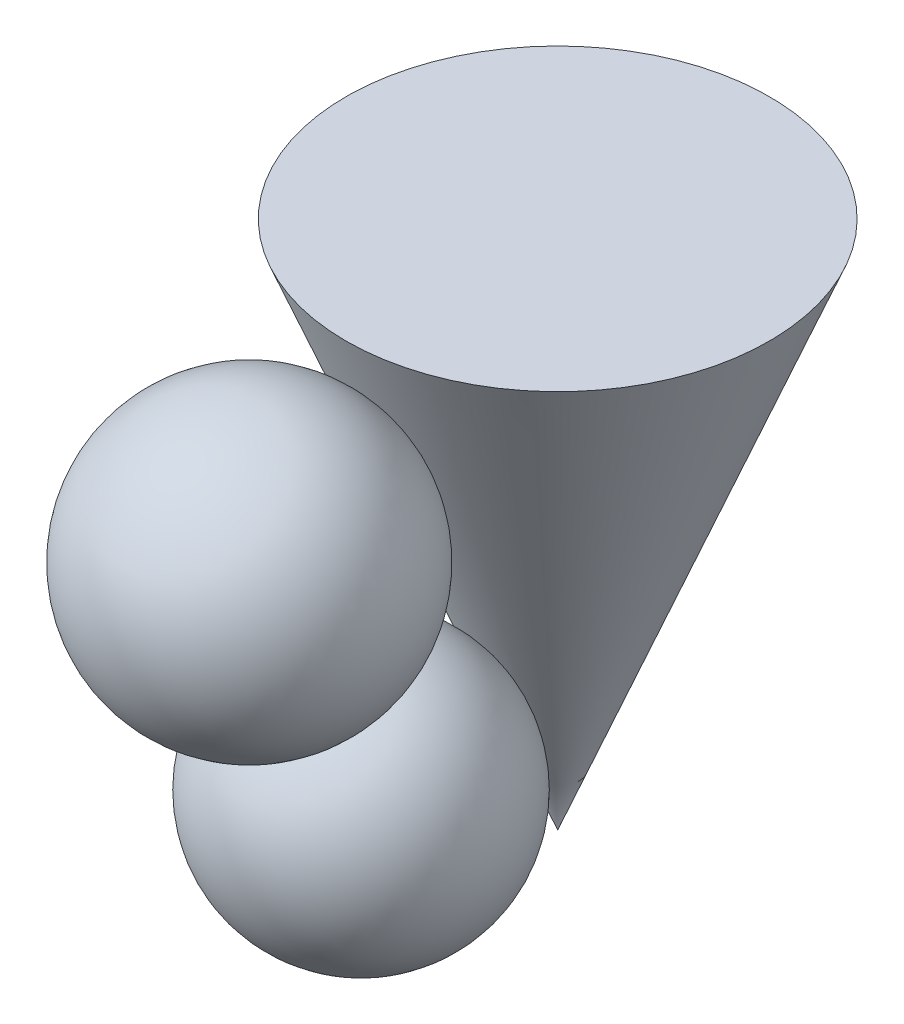
from build123d import *

# Parameters (mm, degrees)
SKETCH2_R = 40


with BuildPart() as part:
    # Sketch2 → Cone section 0
    with BuildSketch(Plane(origin=(0, 100, 0), x_dir=(-1, 0, 0), z_dir=(0, 1, 0)), mode=Mode.PRIVATE) as cone_s0:
        Circle(SKETCH2_R)
    loft([cone_s0.sketch, Vertex(0, 0, 0)])


with BuildPart() as body_2:
    # Sketch5 → SphereB (revolve)
    with BuildSketch(Plane.XY.offset(58.278289835)):
        with BuildLine():
            Line((0, 100), (0, 45.837363086))
            ThreePointArc((0, 45.837363086), (27.081318457, 72.918681543), (0, 100))
        make_face()
    revolve(axis=Axis((0, 100, 58.278289835), (0, -1, 0)))


with BuildPart() as body_3:
    # Sketch7 → SphereA (revolve)
    with BuildSketch(Plane.XY.offset(37.162282055)):
        with BuildLine():
            Line((0, 50.320179747), (0, 0))
            ThreePointArc((0, 0), (25.160089873, 25.160089873), (0, 50.320179747))
        make_face()
    revolve(axis=Axis((0, 50.320179747, 37.162282055), (0, -1, 0)))


solid = Compound([part.part, body_2.part, body_3.part])
